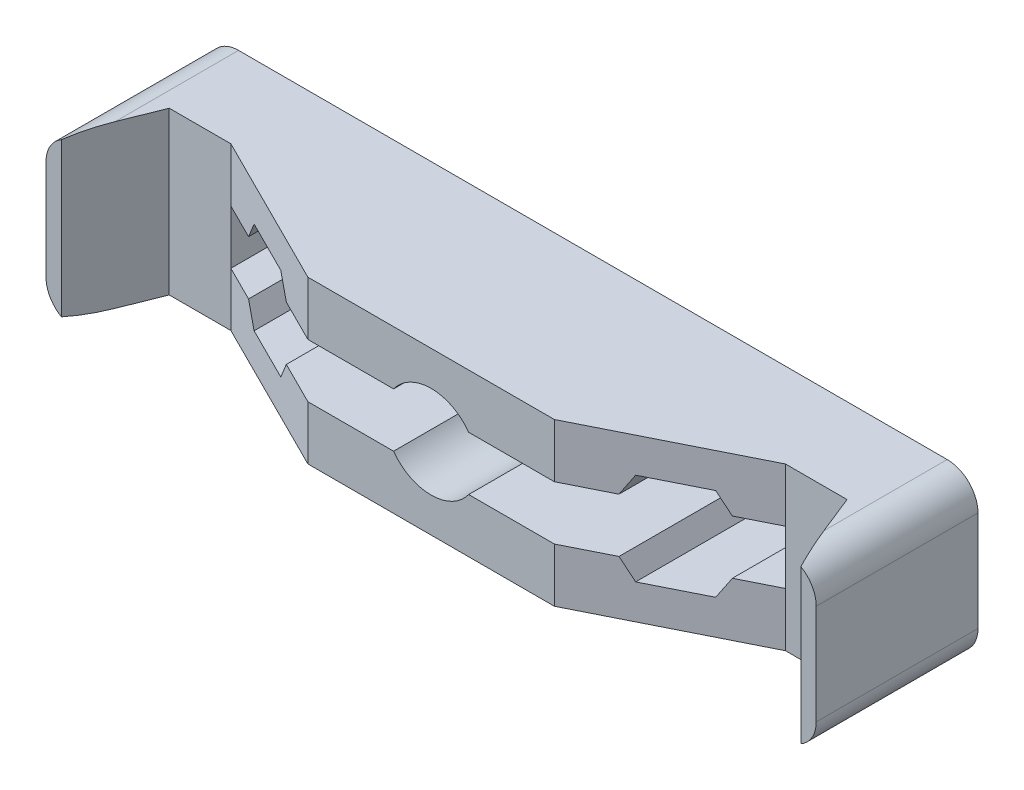
from build123d import *

# Parameters (mm, degrees)
SKETCH_1_W          = 50
SKETCH_1_H          = 10.5
EXTRUDE_1_DEPTH     = 17
SKETCH_2_W          = 36
SKETCH_2_H          = 3.5
CUT_EXTRUDE_1_DEPTH = 10
CUT_EXTRUDE_2_DEPTH = 10.5
SKETCH_4_W          = 3.5
SKETCH_4_H          = 6.5
CUT_EXTRUDE_3_DEPTH = 6.5
FILLET_1_R          = 2
SKETCH_6_R          = 3
SKETCH_6_R_2        = 1.75
CUT_EXTRUDE_4_DEPTH = 18
CUT_EXTRUDE_5_DEPTH = 11
CUT_EXTRUDE_6_DEPTH = 3
SKETCH_9_W          = 58.421136066
SKETCH_9_H          = 24.245128271
CUT_EXTRUDE_7_DEPTH = 7.5


with BuildPart() as part:
    # ｽｹｯﾁ1 → ﾎﾞｽ - 押し出し1 (new body)
    with BuildSketch(Plane.XY):
        with Locations((25, 5.25)):
            Rectangle(SKETCH_1_W, SKETCH_1_H)
    extrude(amount=EXTRUDE_1_DEPTH)

    # ｽｹｯﾁ2 → ｶｯﾄ - 押し出し1 (cut)
    with BuildSketch(Plane.XY.offset(17)):
        with Locations((25, 5.25)):
            Rectangle(SKETCH_2_W, SKETCH_2_H)
    extrude(amount=-CUT_EXTRUDE_1_DEPTH, mode=Mode.SUBTRACT)

    # ｽｹｯﾁ3 → ｶｯﾄ - 押し出し2 (cut)
    with BuildSketch(Plane.XZ):
        Polygon((1, 17), (3, 12), (7, 12), (17, 17), align=None)
        Polygon((33, 17), (43, 12), (47, 12), (49, 17), align=None)
    extrude(amount=-CUT_EXTRUDE_2_DEPTH, mode=Mode.SUBTRACT)

    # ｽｹｯﾁ4 → ｶｯﾄ - 押し出し3 (cut)
    with BuildSketch(Plane(origin=(0, 0, 0), x_dir=(-1, 0, 0), z_dir=(0, 0, -1))):
        with Locations((-2.15, 5.25)):
            Rectangle(SKETCH_4_W, SKETCH_4_H)
        with Locations((-47.85, 5.25)):
            Rectangle(SKETCH_4_W, SKETCH_4_H)
    extrude(amount=-CUT_EXTRUDE_3_DEPTH, mode=Mode.SUBTRACT)

    # ﾌｨﾚｯﾄ1
    fillet_1_edges = [part.edges().sort_by_distance(p)[0] for p in [
        (0, 0, 8.5),
        (0, 10.5, 8.5),
        (50, 0, 8.5),
        (50, 10.5, 8.5),
    ]]
    fillet(fillet_1_edges, radius=FILLET_1_R)

    # ｽｹｯﾁ6 → ｶｯﾄ - 押し出し4 (cut, through all)
    with BuildSketch(Plane(origin=(0, 0, 0), x_dir=(-1, 0, 0), z_dir=(0, 0, -1))):
        with Locations((-25, 5.25)):
            Circle(SKETCH_6_R)
        with Locations((-11.75, 5.25)):
            Circle(SKETCH_6_R_2)
        with Locations((-38.25, 5.25)):
            Circle(SKETCH_6_R_2)
    extrude(amount=-CUT_EXTRUDE_4_DEPTH, mode=Mode.SUBTRACT)

    # ｽｹｯﾁ7 → ｶｯﾄ - 押し出し5 (cut, through all)
    with BuildSketch(Plane.XY.offset(7)):
        Polygon((34.785898385, 5.25), (36.517949192, 2.25), (39.982050808, 2.25), (41.714101615, 5.25), (39.982050808, 8.25), (36.517949192, 8.25), align=None)
        Polygon((13.482050808, 8.25), (15.214101615, 5.25), (13.482050808, 2.25), (10.017949192, 2.25), (8.285898385, 5.25), (10.017949192, 8.25), align=None)
    extrude(amount=CUT_EXTRUDE_5_DEPTH, mode=Mode.SUBTRACT)

    # ｽｹｯﾁ8 → ｶｯﾄ - 押し出し6 (cut)
    with BuildSketch(Plane.XY.offset(7)):
        Polygon((36.517949192, 2.25), (39.982050808, 2.25), (41.714101615, 5.25), (39.982050808, 8.25), (36.517949192, 8.25), (34.785898385, 5.25), align=None)
        Polygon((15.214101615, 5.25), (13.482050808, 2.25), (10.017949192, 2.25), (8.285898385, 5.25), (10.017949192, 8.25), (13.482050808, 8.25), align=None)
    extrude(amount=-CUT_EXTRUDE_6_DEPTH, mode=Mode.SUBTRACT)

    # ｽｹｯﾁ9 → ｶｯﾄ - 押し出し7 (cut, through all)
    with BuildSketch(Plane(origin=(0, 0, 6.5), x_dir=(-1, 0, 0), z_dir=(0, 0, -1))):
        with Locations((-24.970881096, 5.810967265)):
            Rectangle(SKETCH_9_W, SKETCH_9_H)
    extrude(amount=CUT_EXTRUDE_7_DEPTH, mode=Mode.SUBTRACT)


solid = part.part
